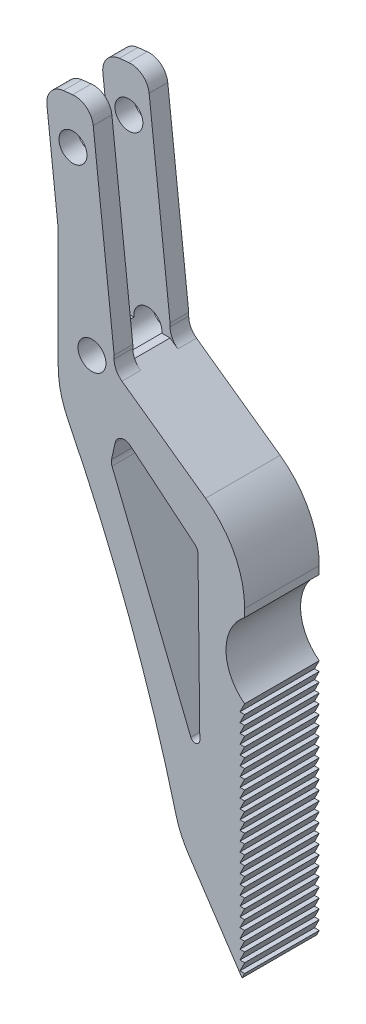
from build123d import *

# Parameters (mm, degrees)
BOSS_EXTRUDE1_DEPTH     = 4
SKETCH2_W               = 20
SKETCH2_H               = 25
CUT_EXTRUDE1_DEPTH      = 2
CUT_EXTRUDE2_DEPTH      = 1
CUT_EXTRUDE2_DEPTH_BACK = 9
CUT_EXTRUDE3_DEPTH      = 9
LPATTERN2_COUNT         = 26
LPATTERN2_PITCH         = 1.0025
CUT_EXTRUDE4_DEPTH      = 9
CUT_EXTRUDE5_DEPTH      = 9
FILLET1_R               = 10
FILLET2_R               = 2
FILLET3_R               = 1
FILLET4_R               = 0.5
SKETCH7_R               = 1.5
CUT_EXTRUDE6_DEPTH      = 9.0000001


with BuildPart() as part:
    # Sketch1 → Boss-Extrude1 (new body, symmetric)
    with BuildSketch(Plane.XY):
        Polygon((0, 0), (-20, 30.005392849), (-20, 60.135392849), (-21.435566599, 73.055886204), (-16.466146078, 73.608027203), (-14.000284373, 51.414595156), (-14.000284373, 50.014595156), (0, 40.028289364), align=None)
    extrude(amount=BOSS_EXTRUDE1_DEPTH, both=True)

    # Sketch2 → Cut-Extrude1 (cut, symmetric)
    with BuildSketch(Plane.XY):
        with Locations((-24.000284373, 62.514595156)):
            Rectangle(SKETCH2_W, SKETCH2_H)
    extrude(amount=CUT_EXTRUDE1_DEPTH, both=True, mode=Mode.SUBTRACT)

    # Sketch3 → Cut-Extrude2 (cut, two sides)
    with BuildSketch(Plane.XY.offset(4)) as cut_extrude2_sk:
        with BuildLine():
            Line((91.496624596, 102.650757811), (0, 34.028289364))
            ThreePointArc((0, 34.028289364), (-2, 30.028289364), (0, 26.028289364))
            Line((0, 26.028289364), (91.496624596, -42.594179083))
            Line((91.496624596, -42.594179083), (320.238186086, -42.594179083))
            Line((320.238186086, -42.594179083), (320.238186086, 102.650757811))
            Line((320.238186086, 102.650757811), (91.496624596, 102.650757811))
        make_face()
    extrude(amount=CUT_EXTRUDE2_DEPTH, mode=Mode.SUBTRACT)
    extrude(cut_extrude2_sk.sketch, amount=-CUT_EXTRUDE2_DEPTH_BACK, mode=Mode.SUBTRACT)

    # Sketch4 → Cut-Extrude3 (cut, through all)
    with BuildSketch(Plane.XY.offset(4)):
        Polygon((0, 26.028289364), (-0.5, 25.028289364), (0, 25.028289364), align=None)
    cut_extrude3 = extrude(amount=-CUT_EXTRUDE3_DEPTH, mode=Mode.SUBTRACT)

    # LPattern2: Cut-Extrude3 ×26
    with Locations(*[(0, -i * LPATTERN2_PITCH, 0) for i in range(1, LPATTERN2_COUNT)]):
        add(cut_extrude3, mode=Mode.SUBTRACT)

    # Sketch5 → Cut-Extrude4 (cut, through all)
    with BuildSketch(Plane.XY.offset(4)):
        with BuildLine():
            Line((-20, 30.005392849), (-6.955074875, 10.434487696))
            ThreePointArc((-6.955074875, 10.434487696), (-12.476218242, 28.097776313), (-20, 45.005392849))
            Line((-20, 45.005392849), (-20, 30.005392849))
        make_face()
    extrude(amount=-CUT_EXTRUDE4_DEPTH, mode=Mode.SUBTRACT)

    # Sketch6 → Cut-Extrude5 (cut, through all)
    with BuildSketch(Plane.XY.offset(4)):
        with BuildLine():
            Line((-13.544369657, 44.932398873), (-5.010201765, 37.897373757))
            Line((-5.010201765, 37.897373757), (-4.779170601, 17.572398873))
            add(Edge.make_bspline(
                [(-4.779170601, 17.572398873), (-14.345858132, 41.272398873)],
                knots=[0, 0, 1, 1], degree=1))
            Line((-14.345858132, 41.272398873), (-13.544369657, 44.932398873))
        make_face()
    extrude(amount=-CUT_EXTRUDE5_DEPTH, mode=Mode.SUBTRACT)

    # Fillet1
    fillet1_edges = [part.edges().sort_by_distance(p)[0] for p in [
        (0, 40.028289364, 0),
        (-20, 45.005392849, 0),
        (-6.955074875, 10.434487696, 0),
    ]]
    fillet(fillet1_edges, radius=FILLET1_R)

    # Fillet2
    fillet2_edges = [part.edges().sort_by_distance(p)[0] for p in [
        (-21.435566599, 73.055886204, 3),
        (-16.466146078, 73.608027203, 3),
        (-14.000284373, 50.014595156, 3),
        (-21.435566599, 73.055886204, -3),
        (-16.466146078, 73.608027203, -3),
        (-14.000284373, 50.014595156, -3),
    ]]
    fillet(fillet2_edges, radius=FILLET2_R)

    # Fillet3
    fillet3_edges = [part.edges().sort_by_distance(p)[0] for p in [
        (-14.345858132, 41.272398873, 0),
        (-5.010201765, 37.897373757, 0),
        (-13.544369657, 44.932398873, 0),
    ]]
    fillet(fillet3_edges, radius=FILLET3_R)

    # Fillet4
    fillet4_edges = [part.edges().sort_by_distance(p)[0] for p in [
        (-4.779170601, 17.572398873, 0),
    ]]
    fillet(fillet4_edges, radius=FILLET4_R)

    # Sketch7 → Cut-Extrude6 (cut, through all)
    with BuildSketch(Plane.XY.offset(4)):
        with Locations((-18.416383851, 68.521557639)):
            Circle(SKETCH7_R)
        with Locations((-16.381192126, 50.204273598)):
            Circle(SKETCH7_R)
    extrude(amount=-CUT_EXTRUDE6_DEPTH, mode=Mode.SUBTRACT)


solid = part.part
